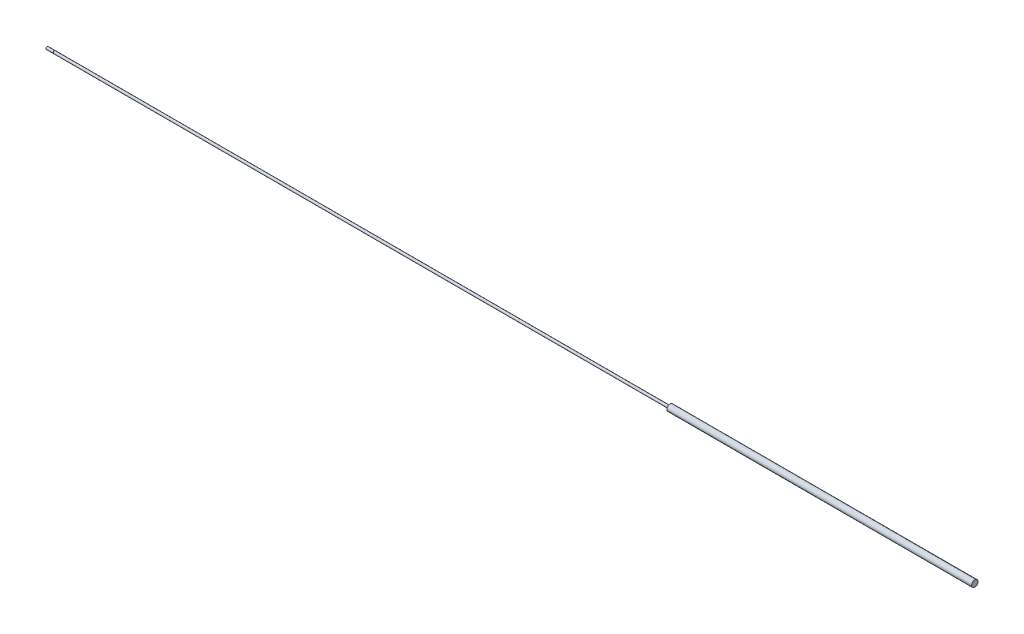
from build123d import *

# Parameters (mm, degrees)
SKETCH3_W = 0.254
SKETCH3_H = 0.508


with BuildPart() as part:
    # Sketch1 → Revolve1 (revolve)
    with BuildSketch(Plane.XY):
        Polygon((0, 0), (0, 1.5875), (777.875, 1.5875), (777.875, 4.03225), (1163.1168, 4.03225), (1163.1168, 0), align=None)
    revolve(axis=Axis((1163.1168, 0, 0), (-1, 0, 0)))

    # Sketch2 → Revolve2 (revolve)
    with BuildSketch(Plane.XY):
        Polygon((-9.652, 0), (-9.652, 1.20904), (-9.27354, 1.5875), (0, 1.5875), (0, 0), align=None)
    revolve(axis=Axis((0, 0, 0), (-1, 0, 0)))

    # Sketch3 → Cut-Revolve1 (revolve, cut)
    with BuildSketch(Plane.XY):
        with Locations((-0.127, 1.5875)):
            Rectangle(SKETCH3_W, SKETCH3_H)
    revolve(axis=Axis((0, 0, 0), (-1, 0, 0)), mode=Mode.SUBTRACT)


solid = part.part
